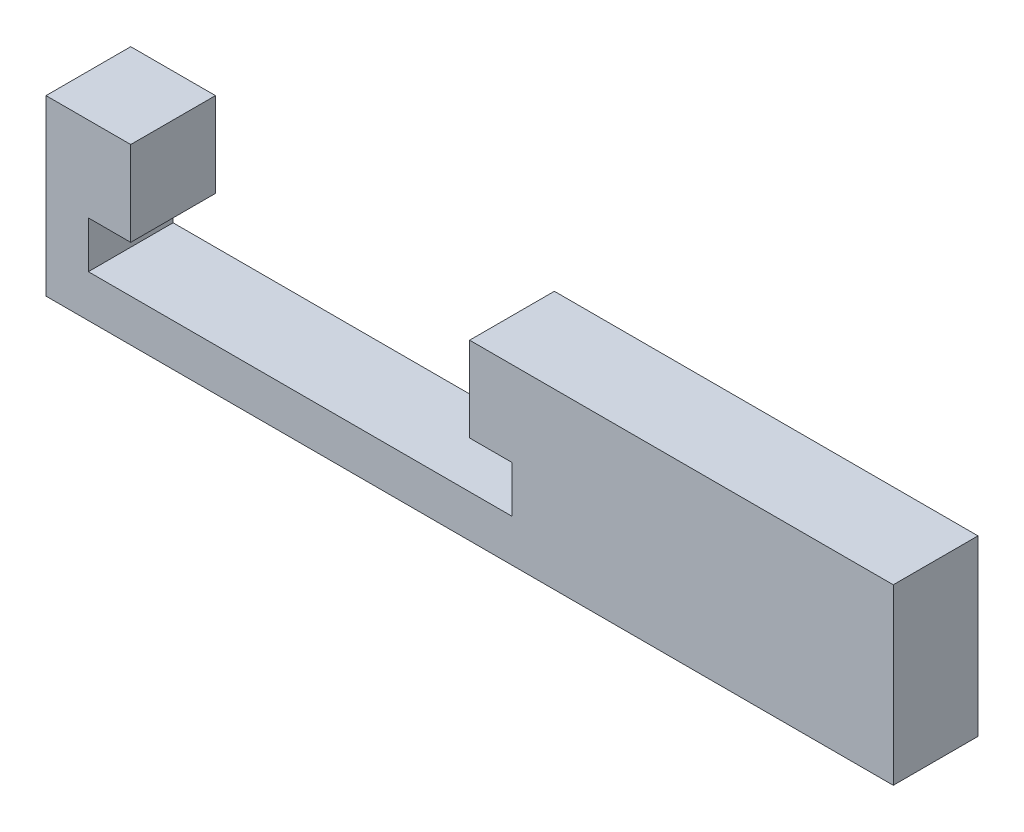
from build123d import *

# Parameters (mm, degrees)
BOSS_EXTRUDE1_DEPTH = 5.08


with BuildPart() as part:
    # Sketch1 → Boss-Extrude1 (new body)
    with BuildSketch(Plane.XY):
        Polygon((-12.7, 0), (12.7, 0), (12.7, 2.794), (10.16, 2.794), (10.16, 7.874), (15.24, 7.874), (35.56, 7.874), (35.56, -2.54), (15.24, -2.54), (-15.24, -2.54), (-15.24, 7.874), (-10.16, 7.874), (-10.16, 2.794), (-12.7, 2.794), align=None)
    extrude(amount=BOSS_EXTRUDE1_DEPTH)


solid = part.part
